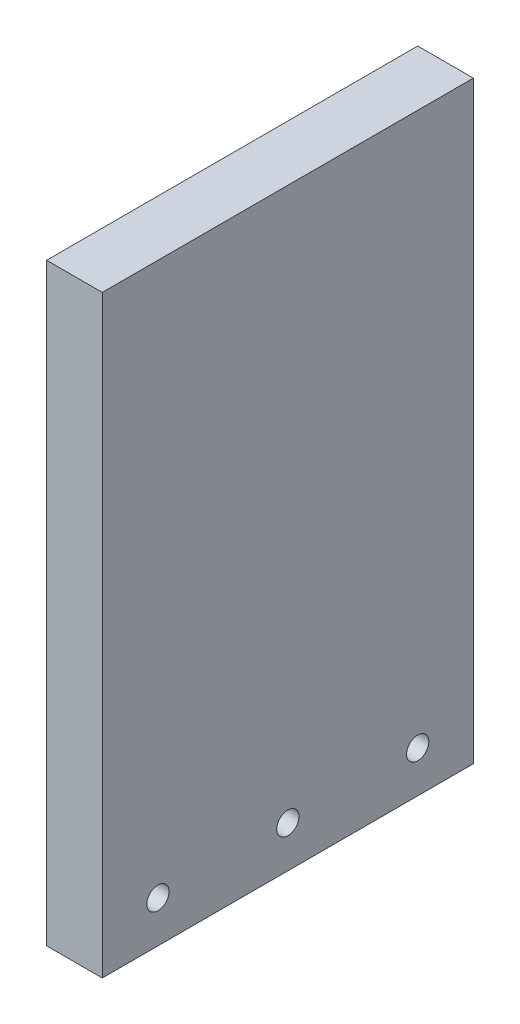
from build123d import *

# Parameters (mm, degrees)
SKETCH1_W           = 19.05
SKETCH1_H           = 127
BOSS_EXTRUDE2_DEPTH = 203.2
SKETCH2_R           = 3.81
CUT_EXTRUDE1_DEPTH  = 88.138


with BuildPart() as part:
    # Sketch1 → Boss-Extrude2 (new body)
    with BuildSketch(Plane(origin=(0, 0, 0), x_dir=(1, 0, 0), z_dir=(0, 1, 0))):
        with Locations((9.525, 63.5)):
            Rectangle(SKETCH1_W, SKETCH1_H)
    extrude(amount=BOSS_EXTRUDE2_DEPTH)

    # Sketch2 → Cut-Extrude1 (cut)
    with BuildSketch(Plane.ZY):
        with Locations((-107.95, 14.224)):
            Circle(SKETCH2_R)
        with Locations((-63.5, 14.224)):
            Circle(SKETCH2_R)
        with Locations((-19.05, 14.224)):
            Circle(SKETCH2_R)
    extrude(amount=-CUT_EXTRUDE1_DEPTH, mode=Mode.SUBTRACT)


solid = part.part
